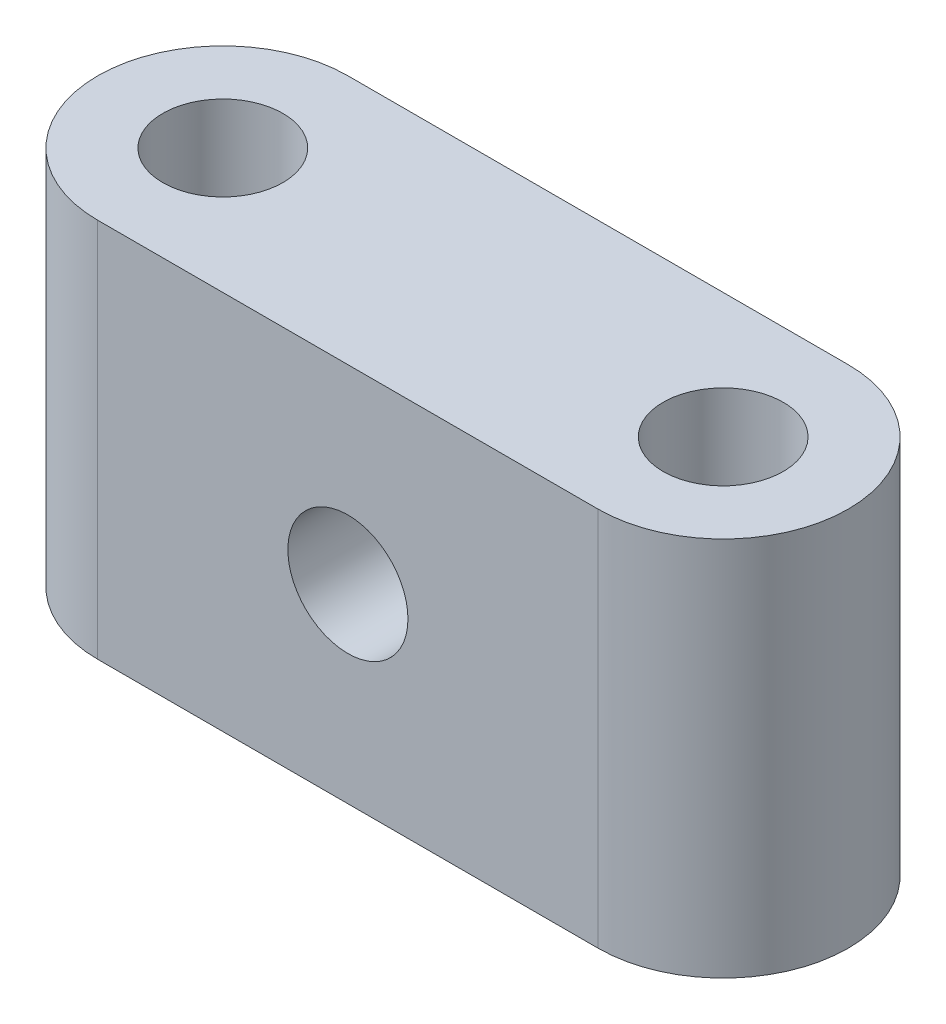
from build123d import *

# Parameters (mm, degrees)
SKETCH1_R           = 6
BOSS_EXTRUDE1_DEPTH = 38
SKETCH3_R           = 6
CUT_EXTRUDE1_DEPTH  = 38


with BuildPart() as part:
    # Sketch1 → Boss-Extrude1 (new body)
    with BuildSketch(Plane(origin=(0, 0, 0), x_dir=(1, 0, 0), z_dir=(0, 1, 0))):
        with BuildLine():
            Line((0, 12.5), (50, 12.5))
            ThreePointArc((50, 12.5), (62.5, 0), (50, -12.5))
            Line((50, -12.5), (0, -12.5))
            ThreePointArc((0, -12.5), (-12.5, 0), (0, 12.5))
        make_face()
        Circle(SKETCH1_R, mode=Mode.SUBTRACT)
        with Locations((50, 0)):
            Circle(SKETCH1_R, mode=Mode.SUBTRACT)
    extrude(amount=BOSS_EXTRUDE1_DEPTH)

    # Sketch3 → Cut-Extrude1 (cut)
    with BuildSketch(Plane.XY.offset(12.5)):
        with Locations((25, 19)):
            Circle(SKETCH3_R)
    extrude(amount=-CUT_EXTRUDE1_DEPTH, mode=Mode.SUBTRACT)


solid = part.part
